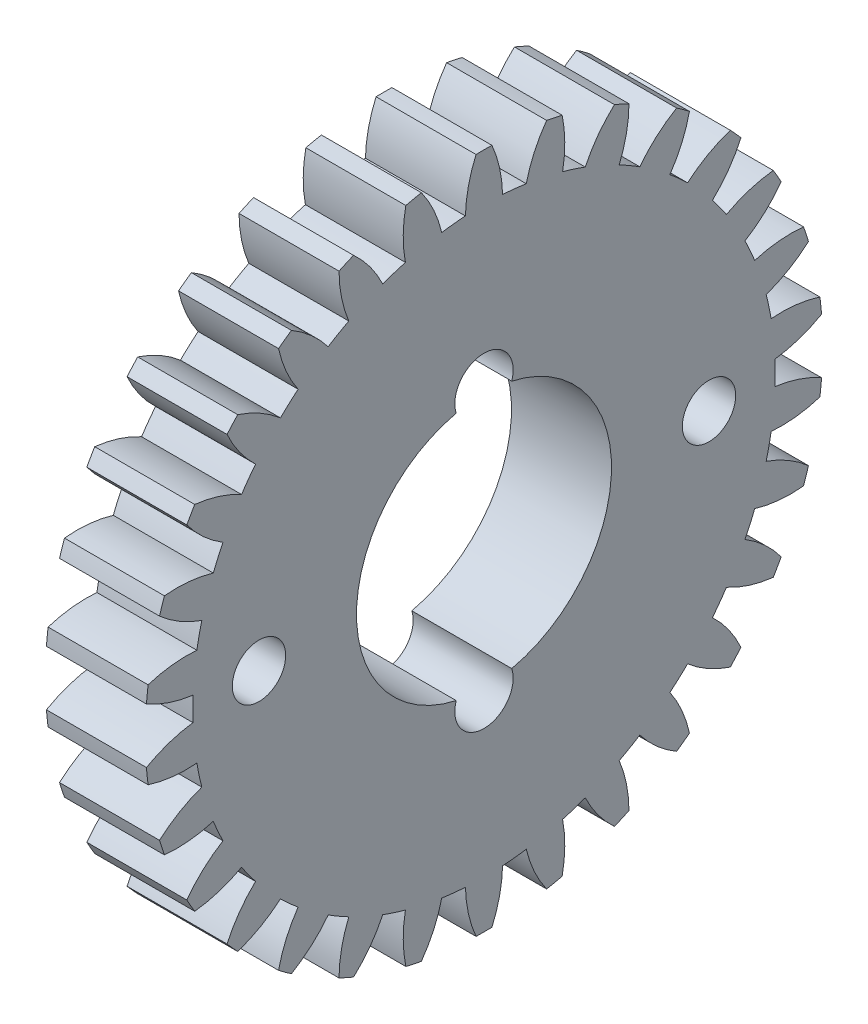
from build123d import *

# Parameters (mm, degrees)
ESBO_O1_R                  = 1.75
ESBO_O1_R_2                = 3
RESSALTO_EXTRUS_O1_DEPTH   = 6
ESBO_O2_R                  = 1.6
ESBO_O2_R_2                = 7.65
CORTE_EXTRUS_O1_DEPTH      = 1
CORTE_EXTRUS_O1_DEPTH_BACK = 7
ESBO_O3_R                  = 3.25
CORTE_EXTRUS_O3_DEPTH      = 3


with BuildPart() as part:
    # Esboço1 → Ressalto-extrusão1 (new body)
    with BuildSketch(Plane(origin=(0, 0, 0), x_dir=(0, -1, 0), z_dir=(-1, 0, 0))):
        with BuildLine():
            ThreePointArc((17.439635583, -1.114327495), (18.908103592, -0.935785134), (20.314403461, -0.476877358))
            ThreePointArc((20.314403461, -0.476877358), (20.32, 0), (20.314403461, 0.476877358))
            ThreePointArc((20.314403461, 0.476877358), (18.908103592, 0.935785134), (17.439635583, 1.114327495))
            ThreePointArc((17.439635583, 1.114327495), (17.379469026, 1.826655801), (17.290219417, 2.535927356))
            ThreePointArc((17.290219417, 2.535927356), (18.689476833, 3.015879804), (19.969633384, 3.757145528))
            ThreePointArc((19.969633384, 3.757145528), (19.875959247, 4.224765557), (19.771336628, 4.690058415))
            ThreePointArc((19.771336628, 4.690058415), (18.300355494, 4.846551772), (16.82685599, 4.715880887))
            ThreePointArc((16.82685599, 4.715880887), (16.619902834, 5.40013378), (16.385137694, 6.075350013))
            ThreePointArc((16.385137694, 6.075350013), (17.654030253, 6.835736324), (18.752094502, 7.826963126))
            ThreePointArc((18.752094502, 7.826963126), (18.563243699, 8.264888587), (18.364167511, 8.698261414))
            ThreePointArc((18.364167511, 8.698261414), (16.892794045, 8.545500841), (15.478662046, 8.111327655))
            ThreePointArc((15.478662046, 8.111327655), (15.133967136, 8.7376), (14.76394683, 9.349250721))
            ThreePointArc((14.76394683, 9.349250721), (15.847017839, 10.356838364), (16.714999109, 11.554704877))
            ThreePointArc((16.714999109, 11.554704877), (16.439225326, 11.943796327), (16.154396153, 12.32630865))
            ThreePointArc((16.154396153, 12.32630865), (14.746936436, 11.870970517), (13.453976295, 11.152270482))
            ThreePointArc((13.453976295, 11.152270482), (12.986604454, 11.693191172), (12.497500644, 12.21454431))
            ThreePointArc((12.497500644, 12.21454431), (13.347414702, 13.42529687), (13.947378047, 14.777450579))
            ThreePointArc((13.947378047, 14.777450579), (13.596733921, 15.100702854), (13.238600165, 15.41563705))
            ThreePointArc((13.238600165, 15.41563705), (11.956566942, 14.677621818), (10.841287221, 13.705805574))
            ThreePointArc((10.841287221, 13.705805574), (10.271664841, 14.13773378), (9.68485371, 14.546003701))
            ThreePointArc((9.68485371, 14.546003701), (10.264465495, 15.907005481), (10.570189637, 17.354350781))
            ThreePointArc((10.570189637, 17.354350781), (10.16, 17.597636205), (9.744213824, 17.831228139))
            ThreePointArc((9.744213824, 17.831228139), (8.643638098, 16.842790615), (7.754781873, 15.660331195))
            ThreePointArc((7.754781873, 15.660331195), (7.107804185, 15.964389581), (6.448932196, 16.24173293))
            ThreePointArc((6.448932196, 16.24173293), (6.732909891, 17.693501623), (6.731033219, 19.172782579))
            ThreePointArc((6.731033219, 19.172782579), (6.279225326, 19.325468411), (5.823958582, 19.467508994))
            ThreePointArc((5.823958582, 19.467508994), (4.952940792, 18.271848642), (4.329355346, 16.930425196))
            ThreePointArc((4.329355346, 16.930425196), (3.633298379, 17.093324952), (2.931161399, 17.227620494))
            ThreePointArc((2.931161399, 17.227620494), (2.907093817, 18.70670684), (2.59769835, 20.153271776))
            ThreePointArc((2.59769835, 20.153271776), (2.124018374, 20.208684914), (1.649168402, 20.252966291))
            ThreePointArc((1.649168402, 20.252966291), (1.045776207, 18.902339204), (0.714715216, 17.460578375))
            ThreePointArc((0.714715216, 17.460578375), (0, 17.4752), (-0.714715216, 17.460578375))
            ThreePointArc((-0.714715216, 17.460578375), (-1.045776207, 18.902339204), (-1.649168402, 20.252966291))
            ThreePointArc((-1.649168402, 20.252966291), (-2.124018374, 20.208684914), (-2.59769835, 20.153271776))
            ThreePointArc((-2.59769835, 20.153271776), (-2.907093817, 18.70670684), (-2.931161399, 17.227620494))
            ThreePointArc((-2.931161399, 17.227620494), (-3.633298379, 17.093324952), (-4.329355346, 16.930425196))
            ThreePointArc((-4.329355346, 16.930425196), (-4.952940792, 18.271848642), (-5.823958582, 19.467508994))
            ThreePointArc((-5.823958582, 19.467508994), (-6.279225326, 19.325468411), (-6.731033219, 19.172782579))
            ThreePointArc((-6.731033219, 19.172782579), (-6.732909891, 17.693501623), (-6.448932196, 16.24173293))
            ThreePointArc((-6.448932196, 16.24173293), (-7.107804185, 15.964389581), (-7.754781873, 15.660331195))
            ThreePointArc((-7.754781873, 15.660331195), (-8.643638098, 16.842790615), (-9.744213824, 17.831228139))
            ThreePointArc((-9.744213824, 17.831228139), (-10.16, 17.597636205), (-10.570189637, 17.354350781))
            ThreePointArc((-10.570189637, 17.354350781), (-10.264465495, 15.907005481), (-9.68485371, 14.546003701))
            ThreePointArc((-9.68485371, 14.546003701), (-10.271664841, 14.13773378), (-10.841287221, 13.705805574))
            ThreePointArc((-10.841287221, 13.705805574), (-11.956566942, 14.677621818), (-13.238600165, 15.41563705))
            ThreePointArc((-13.238600165, 15.41563705), (-13.596733921, 15.100702854), (-13.947378047, 14.777450579))
            ThreePointArc((-13.947378047, 14.777450579), (-13.347414702, 13.42529687), (-12.497500644, 12.21454431))
            ThreePointArc((-12.497500644, 12.21454431), (-12.986604454, 11.693191172), (-13.453976295, 11.152270482))
            ThreePointArc((-13.453976295, 11.152270482), (-14.746936436, 11.870970517), (-16.154396153, 12.32630865))
            ThreePointArc((-16.154396153, 12.32630865), (-16.439225326, 11.943796327), (-16.714999109, 11.554704877))
            ThreePointArc((-16.714999109, 11.554704877), (-15.847017839, 10.356838364), (-14.76394683, 9.349250721))
            ThreePointArc((-14.76394683, 9.349250721), (-15.133967136, 8.7376), (-15.478662046, 8.111327655))
            ThreePointArc((-15.478662046, 8.111327655), (-16.892794045, 8.545500841), (-18.364167511, 8.698261414))
            ThreePointArc((-18.364167511, 8.698261414), (-18.563243699, 8.264888587), (-18.752094502, 7.826963126))
            ThreePointArc((-18.752094502, 7.826963126), (-17.654030253, 6.835736324), (-16.385137694, 6.075350013))
            ThreePointArc((-16.385137694, 6.075350013), (-16.619902834, 5.40013378), (-16.82685599, 4.715880887))
            ThreePointArc((-16.82685599, 4.715880887), (-18.300355494, 4.846551772), (-19.771336628, 4.690058415))
            ThreePointArc((-19.771336628, 4.690058415), (-19.875959247, 4.224765557), (-19.969633384, 3.757145528))
            ThreePointArc((-19.969633384, 3.757145528), (-18.689476833, 3.015879804), (-17.290219417, 2.535927356))
            ThreePointArc((-17.290219417, 2.535927356), (-17.379469026, 1.826655801), (-17.439635583, 1.114327495))
            ThreePointArc((-17.439635583, 1.114327495), (-18.908103592, 0.935785134), (-20.314403461, 0.476877358))
            ThreePointArc((-20.314403461, 0.476877358), (-20.32, 0), (-20.314403461, -0.476877358))
            ThreePointArc((-20.314403461, -0.476877358), (-18.908103592, -0.935785134), (-17.439635583, -1.114327495))
            ThreePointArc((-17.439635583, -1.114327495), (-17.379469026, -1.826655801), (-17.290219417, -2.535927356))
            ThreePointArc((-17.290219417, -2.535927356), (-18.689476833, -3.015879804), (-19.969633384, -3.757145528))
            ThreePointArc((-19.969633384, -3.757145528), (-19.875959247, -4.224765557), (-19.771336628, -4.690058415))
            ThreePointArc((-19.771336628, -4.690058415), (-18.300355494, -4.846551772), (-16.82685599, -4.715880887))
            ThreePointArc((-16.82685599, -4.715880887), (-16.619902834, -5.40013378), (-16.385137694, -6.075350013))
            ThreePointArc((-16.385137694, -6.075350013), (-17.654030253, -6.835736324), (-18.752094502, -7.826963126))
            ThreePointArc((-18.752094502, -7.826963126), (-18.563243699, -8.264888587), (-18.364167511, -8.698261414))
            ThreePointArc((-18.364167511, -8.698261414), (-16.892794045, -8.545500841), (-15.478662046, -8.111327655))
            ThreePointArc((-15.478662046, -8.111327655), (-15.133967136, -8.7376), (-14.76394683, -9.349250721))
            ThreePointArc((-14.76394683, -9.349250721), (-15.847017839, -10.356838364), (-16.714999109, -11.554704877))
            ThreePointArc((-16.714999109, -11.554704877), (-16.439225326, -11.943796327), (-16.154396153, -12.32630865))
            ThreePointArc((-16.154396153, -12.32630865), (-14.746936436, -11.870970517), (-13.453976295, -11.152270482))
            ThreePointArc((-13.453976295, -11.152270482), (-12.986604454, -11.693191172), (-12.497500644, -12.21454431))
            ThreePointArc((-12.497500644, -12.21454431), (-13.347414702, -13.42529687), (-13.947378047, -14.777450579))
            ThreePointArc((-13.947378047, -14.777450579), (-13.596733921, -15.100702854), (-13.238600165, -15.41563705))
            ThreePointArc((-13.238600165, -15.41563705), (-11.956566942, -14.677621818), (-10.841287221, -13.705805574))
            ThreePointArc((-10.841287221, -13.705805574), (-10.271664841, -14.13773378), (-9.68485371, -14.546003701))
            ThreePointArc((-9.68485371, -14.546003701), (-10.264465495, -15.907005481), (-10.570189637, -17.354350781))
            ThreePointArc((-10.570189637, -17.354350781), (-10.16, -17.597636205), (-9.744213824, -17.831228139))
            ThreePointArc((-9.744213824, -17.831228139), (-8.643638098, -16.842790615), (-7.754781873, -15.660331195))
            ThreePointArc((-7.754781873, -15.660331195), (-7.107804185, -15.964389581), (-6.448932196, -16.24173293))
            ThreePointArc((-6.448932196, -16.24173293), (-6.732909891, -17.693501623), (-6.731033219, -19.172782579))
            ThreePointArc((-6.731033219, -19.172782579), (-6.279225326, -19.325468411), (-5.823958582, -19.467508994))
            ThreePointArc((-5.823958582, -19.467508994), (-4.952940792, -18.271848642), (-4.329355346, -16.930425196))
            ThreePointArc((-4.329355346, -16.930425196), (-3.633298379, -17.093324952), (-2.931161399, -17.227620494))
            ThreePointArc((-2.931161399, -17.227620494), (-2.907093817, -18.70670684), (-2.59769835, -20.153271776))
            ThreePointArc((-2.59769835, -20.153271776), (-2.124018374, -20.208684914), (-1.649168402, -20.252966291))
            ThreePointArc((-1.649168402, -20.252966291), (-1.045776207, -18.902339204), (-0.714715216, -17.460578375))
            ThreePointArc((-0.714715216, -17.460578375), (0, -17.4752), (0.714715216, -17.460578375))
            ThreePointArc((0.714715216, -17.460578375), (1.045776207, -18.902339204), (1.649168402, -20.252966291))
            ThreePointArc((1.649168402, -20.252966291), (2.124018374, -20.208684914), (2.59769835, -20.153271776))
            ThreePointArc((2.59769835, -20.153271776), (2.907093817, -18.70670684), (2.931161399, -17.227620494))
            ThreePointArc((2.931161399, -17.227620494), (3.633298379, -17.093324952), (4.329355346, -16.930425196))
            ThreePointArc((4.329355346, -16.930425196), (4.952940792, -18.271848642), (5.823958582, -19.467508994))
            ThreePointArc((5.823958582, -19.467508994), (6.279225326, -19.325468411), (6.731033219, -19.172782579))
            ThreePointArc((6.731033219, -19.172782579), (6.732909891, -17.693501623), (6.448932196, -16.24173293))
            ThreePointArc((6.448932196, -16.24173293), (7.107804185, -15.964389581), (7.754781873, -15.660331195))
            ThreePointArc((7.754781873, -15.660331195), (8.643638098, -16.842790615), (9.744213824, -17.831228139))
            ThreePointArc((9.744213824, -17.831228139), (10.16, -17.597636205), (10.570189637, -17.354350781))
            ThreePointArc((10.570189637, -17.354350781), (10.264465495, -15.907005481), (9.68485371, -14.546003701))
            ThreePointArc((9.68485371, -14.546003701), (10.271664841, -14.13773378), (10.841287221, -13.705805574))
            ThreePointArc((10.841287221, -13.705805574), (11.956566942, -14.677621818), (13.238600165, -15.41563705))
            ThreePointArc((13.238600165, -15.41563705), (13.596733921, -15.100702854), (13.947378047, -14.777450579))
            ThreePointArc((13.947378047, -14.777450579), (13.347414702, -13.42529687), (12.497500644, -12.21454431))
            ThreePointArc((12.497500644, -12.21454431), (12.986604454, -11.693191172), (13.453976295, -11.152270482))
            ThreePointArc((13.453976295, -11.152270482), (14.746936436, -11.870970517), (16.154396153, -12.32630865))
            ThreePointArc((16.154396153, -12.32630865), (16.439225326, -11.943796327), (16.714999109, -11.554704877))
            ThreePointArc((16.714999109, -11.554704877), (15.847017839, -10.356838364), (14.76394683, -9.349250721))
            ThreePointArc((14.76394683, -9.349250721), (15.133967136, -8.7376), (15.478662046, -8.111327655))
            ThreePointArc((15.478662046, -8.111327655), (16.892794045, -8.545500841), (18.364167511, -8.698261414))
            ThreePointArc((18.364167511, -8.698261414), (18.563243699, -8.264888587), (18.752094502, -7.826963126))
            ThreePointArc((18.752094502, -7.826963126), (17.654030253, -6.835736324), (16.385137694, -6.075350013))
            ThreePointArc((16.385137694, -6.075350013), (16.619902834, -5.40013378), (16.82685599, -4.715880887))
            ThreePointArc((16.82685599, -4.715880887), (18.300355494, -4.846551772), (19.771336628, -4.690058415))
            ThreePointArc((19.771336628, -4.690058415), (19.875959247, -4.224765557), (19.969633384, -3.757145528))
            ThreePointArc((19.969633384, -3.757145528), (18.689476833, -3.015879804), (17.290219417, -2.535927356))
            ThreePointArc((17.290219417, -2.535927356), (17.379469026, -1.826655801), (17.439635583, -1.114327495))
        make_face()
        with Locations((8, 0)):
            Circle(ESBO_O1_R, mode=Mode.SUBTRACT)
        Circle(ESBO_O1_R_2, mode=Mode.SUBTRACT)
        with Locations((-8, 0)):
            Circle(ESBO_O1_R, mode=Mode.SUBTRACT)
    extrude(amount=-RESSALTO_EXTRUS_O1_DEPTH)

    # Esboço2 → Corte-extrusão1 (cut, two sides)
    with BuildSketch(Plane(origin=(6, 0, 0), x_dir=(0, 0, -1), z_dir=(1, 0, 0))) as corte_extrus_o1_sk:
        with Locations((-13.5, 0)):
            Circle(ESBO_O2_R)
        with Locations((13.5, 0)):
            Circle(ESBO_O2_R)
        Circle(ESBO_O2_R_2)
    extrude(amount=CORTE_EXTRUS_O1_DEPTH, mode=Mode.SUBTRACT)
    extrude(corte_extrus_o1_sk.sketch, amount=-CORTE_EXTRUS_O1_DEPTH_BACK, mode=Mode.SUBTRACT)

    # Esboço3 → Corte-extrusão3 (cut)
    with BuildSketch(Plane(origin=(0, 0, 0), x_dir=(0, 0, -1), z_dir=(1, 0, 0))):
        with Locations((13.5, 0)):
            Circle(ESBO_O3_R)
        with Locations((-13.5, 0)):
            Circle(ESBO_O3_R)
    extrude(amount=CORTE_EXTRUS_O3_DEPTH, mode=Mode.SUBTRACT)


solid = part.part
